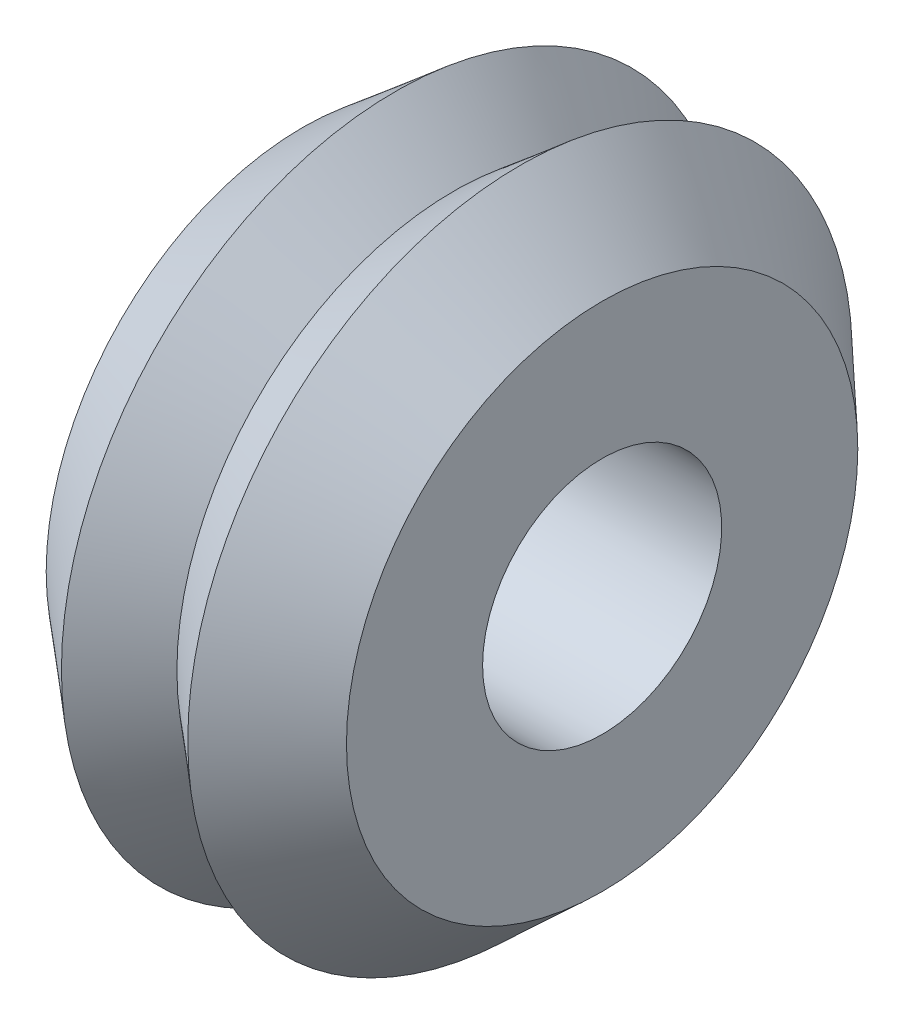
from build123d import *

# Parameters (mm, degrees)
BOSS_EXTRUDE3_DEPTH = 20


with BuildPart() as part:
    # Sketch1 → Revolve-Thin2 (revolve)
    with BuildSketch(Plane.XY):
        Polygon((29.376248058, -59.973392874), (0.560391904, -35.876681975), (-24.659832096, -60.795812358), (-65.01956382, -27.045755372), (-65.01956382, 32.372412999), (65.01956382, 32.372412999), (65.01956382, -26.719075047), align=None)
        Polygon((29.014074927, -46.634880572), (0, -22.372412999), (-25.220224001, -47.291543383), (-55.01956382, -22.372412999), (-55.01956382, 22.372412999), (55.01956382, 22.372412999), (55.01956382, -22.372412999), align=None, mode=Mode.SUBTRACT)
    revolve(axis=Axis((-55.01956382, 84.277813771, 0), (1, 0, 0)))

    # Sketch2 → Boss-Extrude3 (add)
    with BuildSketch(Plane.ZY.offset(65.01956382)):
        with BuildLine():
            Line((-51.905400772, 84.277813771), (-76.712133876, 84.277813771))
            Line((-76.712133876, 84.277813771), (-74.341443656, 89.433234307))
            ThreePointArc((-74.341443656, 89.433234307), (-60.775134761, 106.881443528), (-40.875379676, 116.498329179))
            Line((-40.875379676, 116.498329179), (-40.654960426, 116.547688609))
            Line((-40.654960426, 116.547688609), (-45.427875958, 109.387148992))
            Line((-45.427875958, 109.387148992), (-49.616909483, 99.520284788))
            Line((-49.616909483, 99.520284788), (-51.648739272, 89.433234307))
            Line((-51.648739272, 89.433234307), (-51.905400772, 84.277813771))
        make_face()
        with BuildLine():
            Line((-25.952700386, 129.229209434), (-38.356066938, 150.712470486))
            Line((-38.356066938, 150.712470486), (-32.705996677, 151.2371028))
            ThreePointArc((-32.705996677, 151.2371028), (-10.812249793, 148.212439271), (7.466095028, 135.787188664))
            Line((7.466095028, 135.787188664), (7.619051174, 135.620979709))
            Line((7.619051174, 135.620979709), (-0.968615806, 136.174176002))
            Line((-0.968615806, 136.174176002), (-11.608087624, 134.868553349))
            Line((-11.608087624, 134.868553349), (-21.359644485, 131.584644322))
            Line((-21.359644485, 131.584644322), (-25.952700386, 129.229209434))
        make_face()
        with BuildLine():
            Line((25.952700386, 129.229209434), (38.356066938, 150.712470486))
            Line((38.356066938, 150.712470486), (41.635446979, 146.081682264))
            ThreePointArc((41.635446979, 146.081682264), (49.962884968, 125.608809514), (48.341474704, 103.566673256))
            Line((48.341474704, 103.566673256), (48.2740116, 103.351104871))
            Line((48.2740116, 103.351104871), (44.459260153, 111.064840781))
            Line((44.459260153, 111.064840781), (38.008821859, 119.626082332))
            Line((38.008821859, 119.626082332), (30.289094787, 126.429223787))
            Line((30.289094787, 126.429223787), (25.952700386, 129.229209434))
        make_face()
        with BuildLine():
            Line((51.905400772, 84.277813771), (76.712133876, 84.277813771))
            Line((76.712133876, 84.277813771), (74.341443656, 79.122393235))
            ThreePointArc((74.341443656, 79.122393235), (60.775134761, 61.674184014), (40.875379676, 52.057298364))
            Line((40.875379676, 52.057298364), (40.654960426, 52.007938933))
            Line((40.654960426, 52.007938933), (45.427875958, 59.16847855))
            Line((45.427875958, 59.16847855), (49.616909483, 69.035342754))
            Line((49.616909483, 69.035342754), (51.648739272, 79.122393235))
            Line((51.648739272, 79.122393235), (51.905400772, 84.277813771))
        make_face()
        with BuildLine():
            Line((25.952700386, 39.326418109), (38.356066938, 17.843157056))
            Line((38.356066938, 17.843157056), (32.705996677, 17.318524743))
            ThreePointArc((32.705996677, 17.318524743), (10.812249793, 20.343188271), (-7.466095028, 32.768438879))
            Line((-7.466095028, 32.768438879), (-7.619051174, 32.934647833))
            Line((-7.619051174, 32.934647833), (0.968615806, 32.381451541))
            Line((0.968615806, 32.381451541), (11.608087624, 33.687074193))
            Line((11.608087624, 33.687074193), (21.359644485, 36.97098322))
            Line((21.359644485, 36.97098322), (25.952700386, 39.326418109))
        make_face()
        with BuildLine():
            Line((-25.952700386, 39.326418109), (-38.356066938, 17.843157056))
            Line((-38.356066938, 17.843157056), (-41.635446979, 22.473945279))
            ThreePointArc((-41.635446979, 22.473945279), (-49.962884968, 42.946818028), (-48.341474704, 64.988954286))
            Line((-48.341474704, 64.988954286), (-48.2740116, 65.204522671))
            Line((-48.2740116, 65.204522671), (-44.459260153, 57.490786762))
            Line((-44.459260153, 57.490786762), (-38.008821859, 48.929545211))
            Line((-38.008821859, 48.929545211), (-30.289094787, 42.126403756))
            Line((-30.289094787, 42.126403756), (-25.952700386, 39.326418109))
        make_face()
    extrude(amount=BOSS_EXTRUDE3_DEPTH)


solid = part.part
